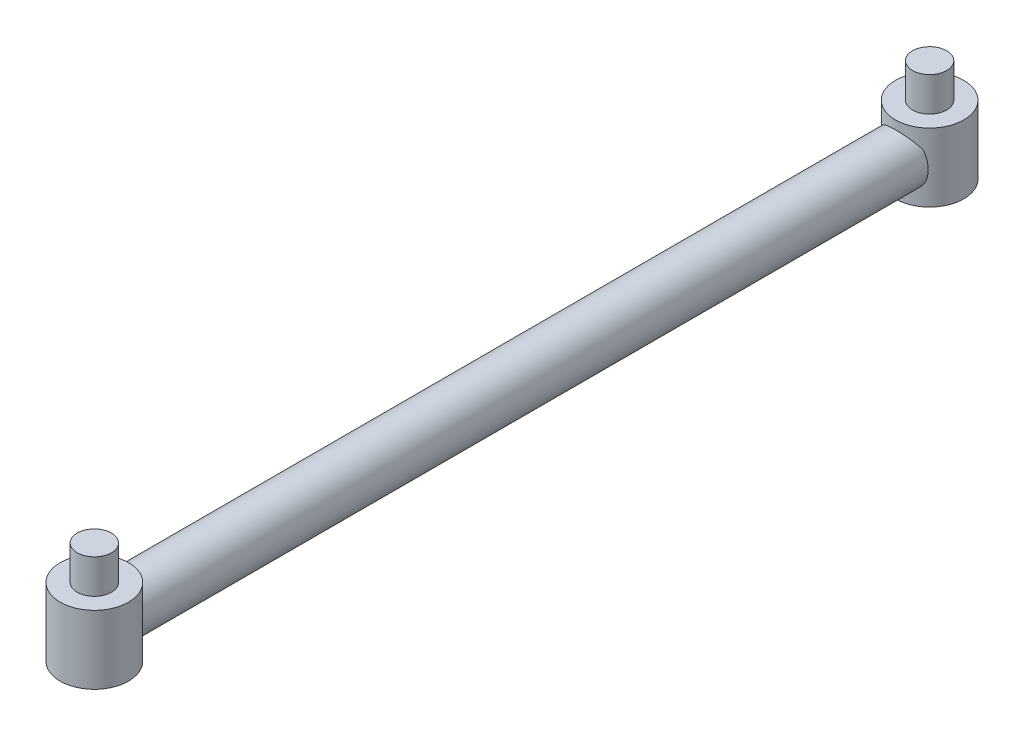
from build123d import *

# Parameters (mm, degrees)
SKIZZE1_R                       = 1.5
AUFSATZ_LINEAR_AUSTRAGEN1_DEPTH = 46
AUFSATZ_LINEAR_START            = -2
SKIZZE2_R                       = 2
AUFSATZ_LINEAR_AUSTRAGEN2_DEPTH = 4
SKIZZE3_R                       = 1
AUFSATZ_LINEAR_AUSTRAGEN4_DEPTH = 2


with BuildPart() as part:
    # Skizze1 → Aufsatz-Linear austragen1 (new body)
    with BuildSketch(Plane.XY):
        Circle(SKIZZE1_R)
    extrude(amount=AUFSATZ_LINEAR_AUSTRAGEN1_DEPTH)

    # Skizze2 → Aufsatz-Linear austragen2 (add)
    with BuildSketch(Plane(origin=(0, 0, 0), x_dir=(1, 0, 0), z_dir=(0, 1, 0)).offset(AUFSATZ_LINEAR_START)):
        with Locations((0, -47.23803597)):
            Circle(SKIZZE2_R)
        with Locations((0, 1.58182535)):
            Circle(SKIZZE2_R)
    extrude(amount=AUFSATZ_LINEAR_AUSTRAGEN2_DEPTH)

    # Skizze3 → Aufsatz-Linear austragen4 (add)
    with BuildSketch(Plane(origin=(0, 2, 0), x_dir=(1, 0, 0), z_dir=(0, 1, 0))):
        with Locations((0, -47.23803597)):
            Circle(SKIZZE3_R)
        with Locations((0, 1.58182535)):
            Circle(SKIZZE3_R)
    extrude(amount=AUFSATZ_LINEAR_AUSTRAGEN4_DEPTH)


solid = part.part
